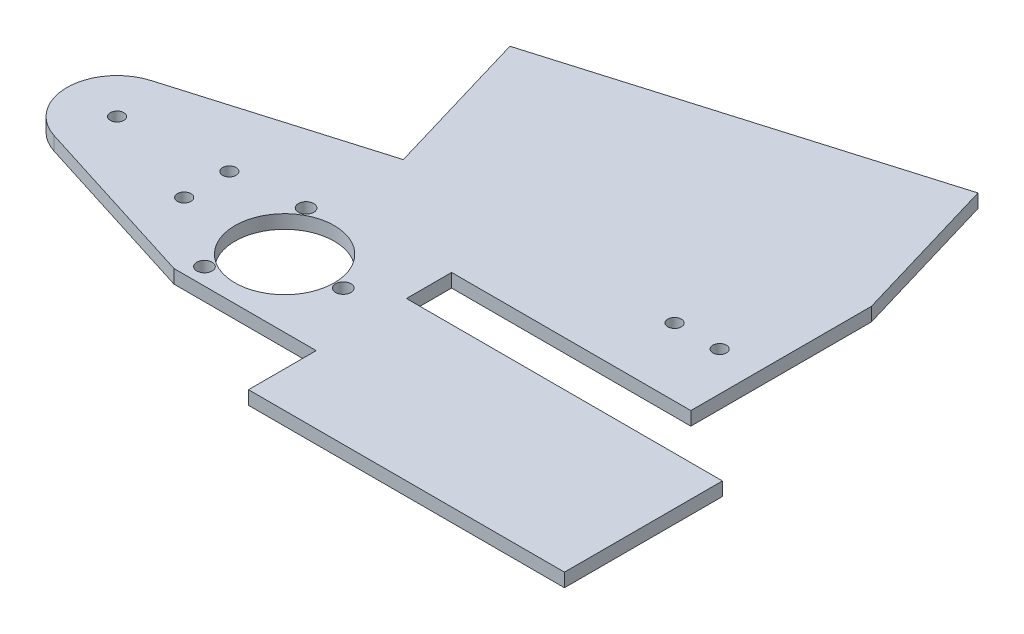
from build123d import *

# Parameters (mm, degrees)
ESQUISSE3_R        = 1.5
ESQUISSE3_R_2      = 11
ESQUISSE3_R_3      = 1.7
BOSS_EXTRU_3_DEPTH = 3


with BuildPart() as part:
    # Esquisse3 → Boss.-Extru.3 (new body)
    with BuildSketch(Plane.XZ):
        with BuildLine():
            Line((-464.844143116, -40.359876935), (-411.844143116, -40.359876935))
            Line((-411.844143116, -40.359876935), (-411.844143116, -80.359876935))
            Line((-411.844143116, -80.359876935), (-421.785994494, -113.91817831))
            Line((-421.785994494, -113.91817831), (-501.785994494, -90.217690572))
            Line((-501.785994494, -90.217690572), (-491.844143116, -56.659389197))
            Line((-491.844143116, -56.659389197), (-534.975651854, -43.881416773))
            ThreePointArc((-534.975651854, -43.881416773), (-542.943725497, -33.306292776), (-535.160059098, -22.594711075))
            Line((-535.160059098, -22.594711075), (-496.344143116, -10.359876935))
            Line((-496.344143116, -10.359876935), (-464.844143116, -10.359876935))
            Line((-464.844143116, -10.359876935), (-464.844143116, 4.640123065))
            Line((-464.844143116, 4.640123065), (-394.844143116, 4.640123065))
            Line((-394.844143116, 4.640123065), (-394.844143116, -30.359876935))
            Line((-394.844143116, -30.359876935), (-464.844143116, -30.359876935))
            Line((-464.844143116, -30.359876935), (-464.844143116, -40.359876935))
        make_face()
        with Locations((-531.814143116, -33.209876935)):
            Circle(ESQUISSE3_R, mode=Mode.SUBTRACT)
        with Locations((-508.844143116, -35.113476935)):
            Circle(ESQUISSE3_R, mode=Mode.SUBTRACT)
        with Locations((-508.844143116, -25.113476935)):
            Circle(ESQUISSE3_R, mode=Mode.SUBTRACT)
        with Locations((-486.844143116, -25.359876935)):
            Circle(ESQUISSE3_R_2, mode=Mode.SUBTRACT)
        with Locations((-473.844143116, -25.359876935)):
            Circle(ESQUISSE3_R_3, mode=Mode.SUBTRACT)
        with Locations((-493.344143116, -36.618207185)):
            Circle(ESQUISSE3_R_3, mode=Mode.SUBTRACT)
        with Locations((-493.344143116, -14.101546686)):
            Circle(ESQUISSE3_R_3, mode=Mode.SUBTRACT)
        with Locations((-420.455543116, -55.359876935)):
            Circle(ESQUISSE3_R, mode=Mode.SUBTRACT)
        with Locations((-430.455543116, -55.359876935)):
            Circle(ESQUISSE3_R, mode=Mode.SUBTRACT)
    extrude(amount=BOSS_EXTRU_3_DEPTH)


solid = part.part
